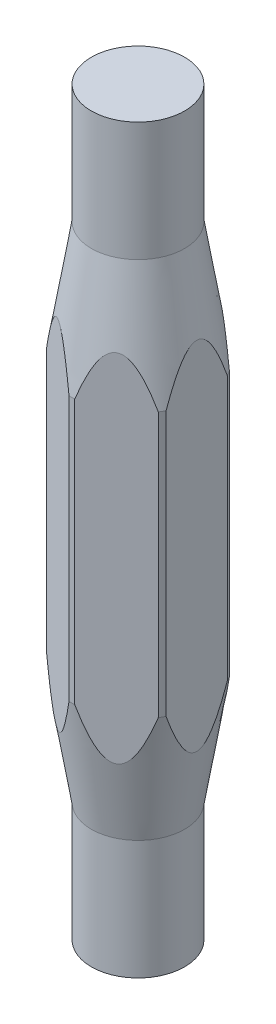
from build123d import *

# Parameters (mm, degrees)
SKETCH3_W                = 0.428843097
SKETCH3_H                = 18.90052945
CUT_EXTRUDE1_DEPTH       = 7.35
CIRPATTERN1_COUNT        = 6
SKETCH5_R                = 2.237093308
BOSS_EXTRUDE1_DEPTH      = 17.78
BOSS_EXTRUDE1_DEPTH_BACK = 17.78


with BuildPart() as part:
    # Sketch1 → Revolve1 (revolve)
    with BuildSketch(Plane.XY):
        Polygon((2.237093308, -12.065), (3.175, -6.35), (3.175, 6.35), (2.237093308, 12.065), align=None)
    revolve(axis=Axis((0, 6.041374164, 0), (0, -1, 0)))

    # Sketch3 → Cut-Extrude1 (cut, through all)
    with BuildSketch(Plane.XY.offset(3.175)):
        with Locations((-3.029889302, -0.659045193)):
            Rectangle(SKETCH3_W, SKETCH3_H)
    cut_extrude1 = extrude(amount=-CUT_EXTRUDE1_DEPTH, mode=Mode.SUBTRACT)

    # CirPattern1: Cut-Extrude1 ×6 about axis
    cirpattern1_axis = Axis((0, 0, 0), (0, 1, 0))
    for i in range(1, CIRPATTERN1_COUNT):
        add(cut_extrude1.rotate(cirpattern1_axis, i * 360 / CIRPATTERN1_COUNT), mode=Mode.SUBTRACT)

    # Sketch5 → Boss-Extrude1 (add, two sides)
    with BuildSketch(Plane(origin=(0, 0, 0), x_dir=(1, 0, 0), z_dir=(0, 1, 0))) as boss_extrude1_sk:
        Circle(SKETCH5_R)
    extrude(amount=BOSS_EXTRUDE1_DEPTH)
    extrude(boss_extrude1_sk.sketch, amount=-BOSS_EXTRUDE1_DEPTH_BACK)


solid = part.part
